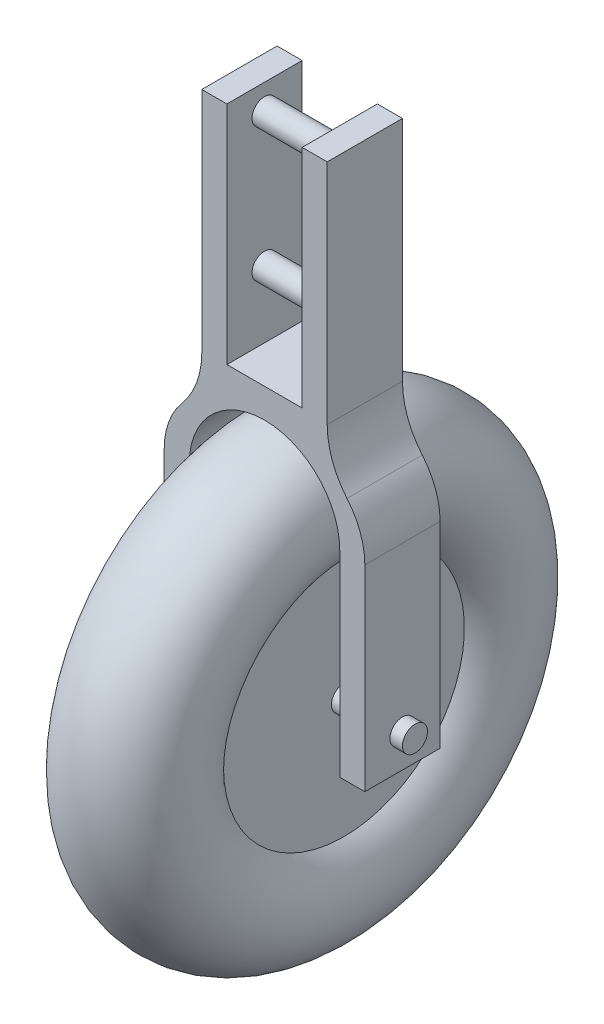
from build123d import *

# Parameters (mm, degrees)
BOSS_EXTRUDE1_DEPTH = 9
SKETCH3_R           = 1.5
BOSS_EXTRUDE2_DEPTH = 13.5
SKETCH2_R           = 1.5
BOSS_EXTRUDE3_DEPTH = 15


with BuildPart() as part:
    # Sketch1 → Boss-Extrude1 (new body)
    with BuildSketch(Plane.XY):
        with BuildLine():
            Line((-7.5, 27), (-4.5, 27))
            Line((-4.5, 27), (-4.5, 0))
            Line((-4.5, 0), (4.5, 0))
            Line((4.5, 0), (4.5, 27))
            Line((4.5, 27), (7.5, 27))
            Line((7.5, 27), (7.5, -0.221970842))
            ThreePointArc((7.5, -0.221970842), (8.110756434, -3.66320685), (9.868421053, -6.684091452))
            ThreePointArc((9.868421053, -6.684091452), (11.450319209, -9.402887593), (12, -12.5))
            Line((12, -12.5), (12, -36))
            Line((12, -36), (9, -36))
            Line((9, -36), (9, -12.5))
            ThreePointArc((9, -12.5), (6.363961031, -6.136038969), (0, -3.5))
            ThreePointArc((0, -3.5), (-6.363961031, -6.136038969), (-9, -12.5))
            Line((-9, -12.5), (-9, -36))
            Line((-9, -36), (-12, -36))
            Line((-12, -36), (-12, -12.5))
            ThreePointArc((-12, -12.5), (-11.450319209, -9.402887593), (-9.868421053, -6.684091452))
            ThreePointArc((-9.868421053, -6.684091452), (-8.110756434, -3.66320685), (-7.5, -0.221970842))
            Line((-7.5, -0.221970842), (-7.5, 27))
        make_face()
    extrude(amount=BOSS_EXTRUDE1_DEPTH)

    # Sketch3 → Boss-Extrude2 (add, symmetric)
    with BuildSketch(Plane(origin=(0, 0, 0), x_dir=(0, 0, -1), z_dir=(1, 0, 0))):
        with Locations((-4.5, -32)):
            Circle(SKETCH3_R)
    extrude(amount=BOSS_EXTRUDE2_DEPTH, both=True)

    # Sketch4 → Revolve1 (revolve)
    with BuildSketch(Plane.XY.offset(4.5)):
        with BuildLine():
            Line((-5, -32), (5, -32))
            Line((5, -32), (5, -17.590169944))
            ThreePointArc((5, -17.590169944), (0, -4.5), (-5, -17.590169944))
            Line((-5, -17.590169944), (-5, -32))
        make_face()
    revolve(axis=Axis((-13.5, -32, 4.5), (1, 0, 0)))

    # Sketch2 → Boss-Extrude3 (add)
    with BuildSketch(Plane(origin=(7.5, 0, 0), x_dir=(0, 0, -1), z_dir=(1, 0, 0))):
        with Locations((-4.5, 24)):
            Circle(SKETCH2_R)
        with Locations((-4.5, 8)):
            Circle(SKETCH2_R)
    extrude(amount=-BOSS_EXTRUDE3_DEPTH)


solid = part.part
